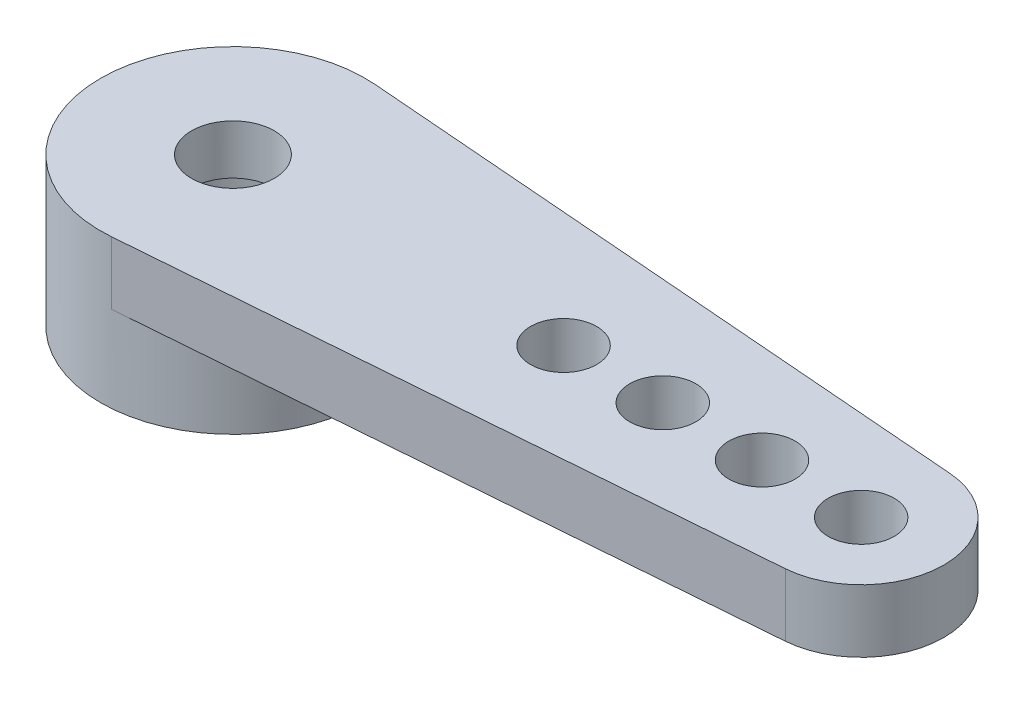
from build123d import *

# Parameters (mm, degrees)
SKETCH_1_R          = 4
SKETCH_1_R_2        = 1.25
EXTRUDE_1_DEPTH     = 4.5
SKETCH_2_R          = 1
EXTRUDE_2_DEPTH     = 1.9
SKETCH_3_R          = 2.4
CUT_EXTRUDE_1_DEPTH = 3


with BuildPart() as part:
    # 草图1 → 凸台-拉伸1 (new body)
    with BuildSketch(Plane(origin=(0, 0, 0), x_dir=(1, 0, 0), z_dir=(0, 1, 0))):
        Circle(SKETCH_1_R)
        Circle(SKETCH_1_R_2, mode=Mode.SUBTRACT)
    extrude(amount=EXTRUDE_1_DEPTH)

    # 草图2 → 凸台-拉伸2 (add)
    with BuildSketch(Plane(origin=(0, 4.5, 0), x_dir=(1, 0, 0), z_dir=(0, 1, 0))):
        with BuildLine():
            Line((19.197368421, 2.492196964), (0.315789474, 3.987515142))
            ThreePointArc((0.315789474, 3.987515142), (4, 0), (0.315789474, -3.987515142))
            Line((0.315789474, -3.987515142), (19.197368421, -2.492196964))
            ThreePointArc((19.197368421, -2.492196964), (21.5, 0), (19.197368421, 2.492196964))
        make_face()
        with Locations((16, 0)):
            Circle(SKETCH_2_R, mode=Mode.SUBTRACT)
        with Locations((10, 0)):
            Circle(SKETCH_2_R, mode=Mode.SUBTRACT)
        with Locations((13, 0)):
            Circle(SKETCH_2_R, mode=Mode.SUBTRACT)
        with Locations((19, 0)):
            Circle(SKETCH_2_R, mode=Mode.SUBTRACT)
    extrude(amount=-EXTRUDE_2_DEPTH)

    # 草图3 → 切除-拉伸1 (cut)
    with BuildSketch(Plane.XZ):
        Circle(SKETCH_3_R)
    extrude(amount=-CUT_EXTRUDE_1_DEPTH, mode=Mode.SUBTRACT)


solid = part.part
